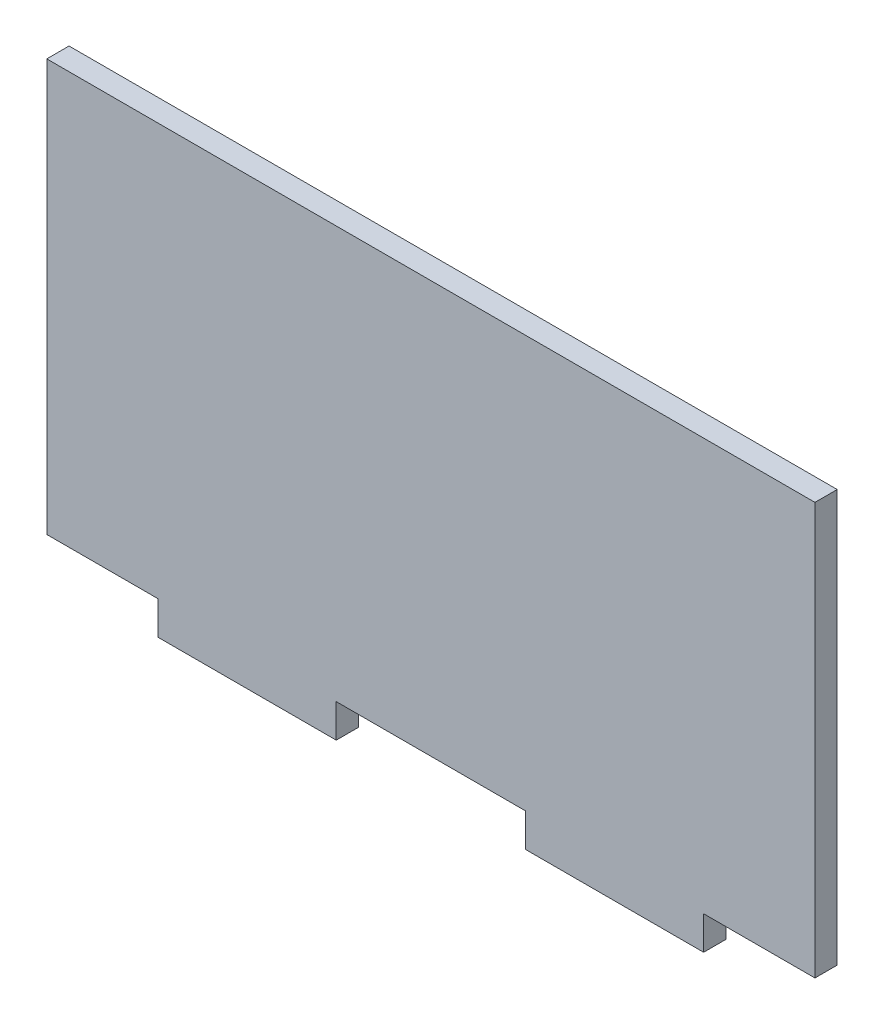
from build123d import *

# Parameters (mm, degrees)
BOSS_EXTRUDE1_DEPTH = 2


with BuildPart() as part:
    # Sketch1 → Boss-Extrude1 (new body)
    with BuildSketch(Plane.XY):
        Polygon((-24.5, -17), (-24.5, -20), (-8.5, -20), (-8.5, -17), (8.5, -17), (8.5, -20), (24.5, -20), (24.5, -17), (34.5, -17), (34.5, 20), (-34.5, 20), (-34.5, -17), align=None)
    extrude(amount=BOSS_EXTRUDE1_DEPTH)


solid = part.part
